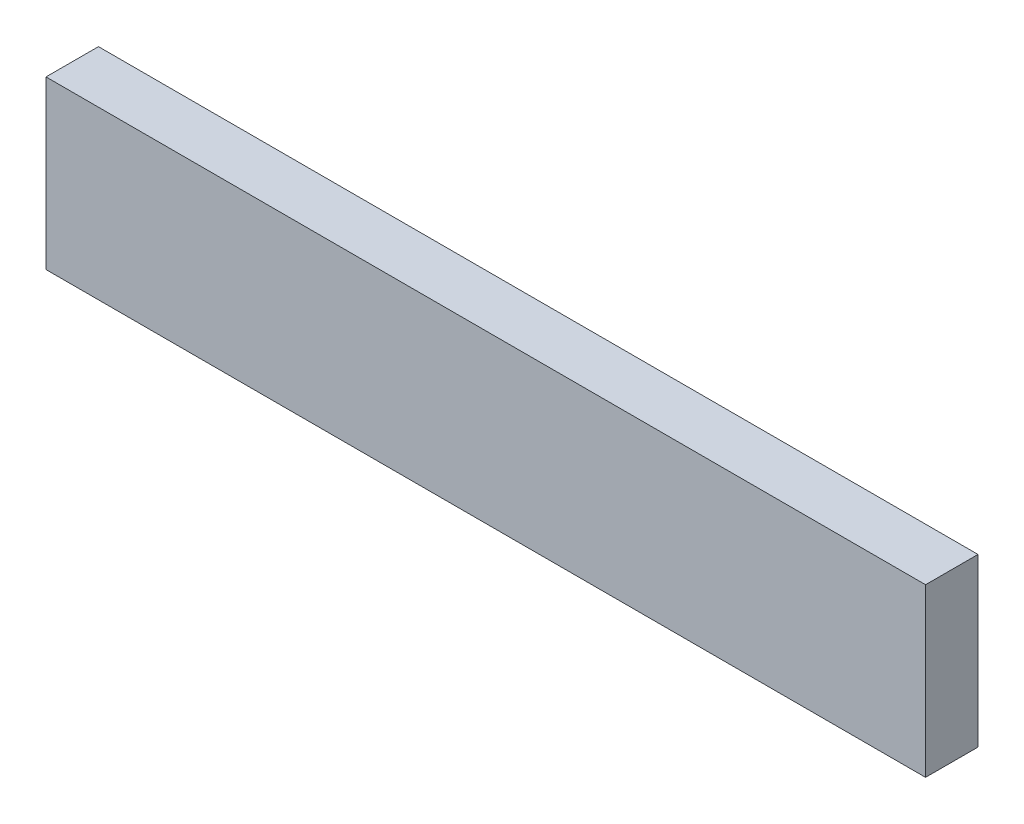
from build123d import *

# Parameters (mm, degrees)
ESQUISSE1_W        = 369
ESQUISSE1_H        = 70
BOSS_EXTRU_1_DEPTH = 22


with BuildPart() as part:
    # Esquisse1 → Boss.-Extru.1 (new body)
    with BuildSketch(Plane.XY):
        Rectangle(ESQUISSE1_W, ESQUISSE1_H)
    extrude(amount=BOSS_EXTRU_1_DEPTH)


solid = part.part
